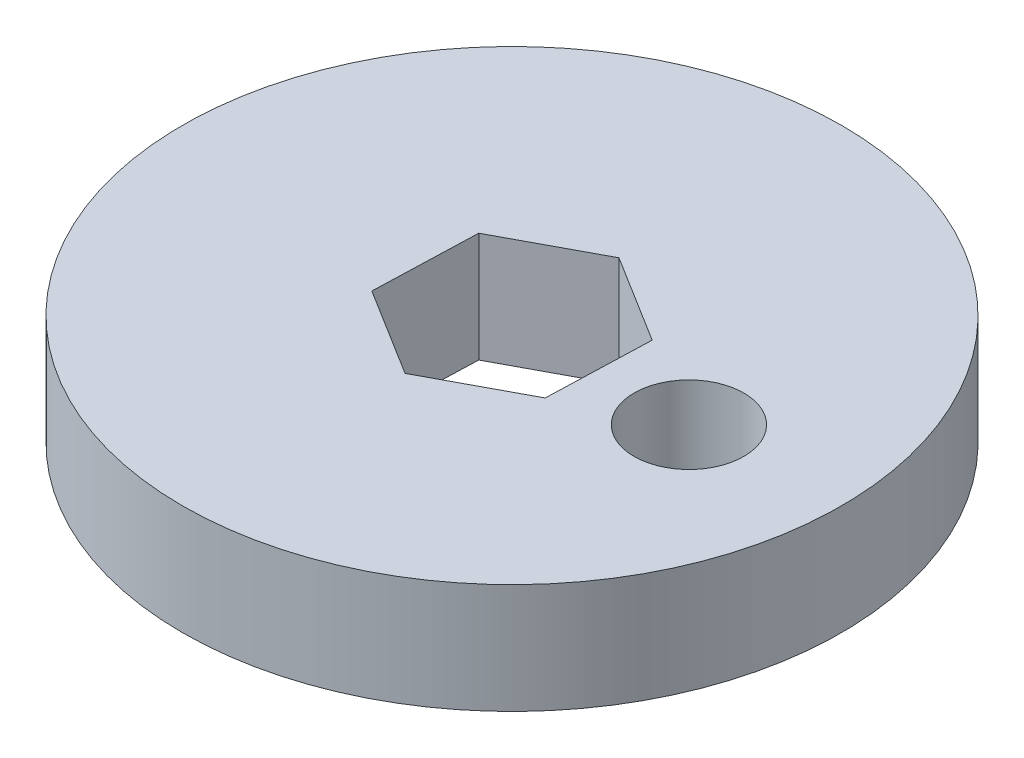
from build123d import *

# Parameters (mm, degrees)
SKETCH1_R           = 9
SKETCH1_R_2         = 1.5
BOSS_EXTRUDE1_DEPTH = 3


with BuildPart() as part:
    # Sketch1 → Boss-Extrude1 (new body)
    with BuildSketch(Plane(origin=(0, 0, 0), x_dir=(1, 0, 0), z_dir=(0, 1, 0))):
        Circle(SKETCH1_R)
        with Locations((4.997281989, -0.164841493)):
            Circle(SKETCH1_R_2, mode=Mode.SUBTRACT)
        Polygon((2.495302102, 1.332966898), (2.402034248, -1.494511561), (-0.093267855, -2.82747846), (-2.495302102, -1.332966898), (-2.402034248, 1.494511561), (0.093267855, 2.82747846), align=None, mode=Mode.SUBTRACT)
    extrude(amount=BOSS_EXTRUDE1_DEPTH)


solid = part.part
